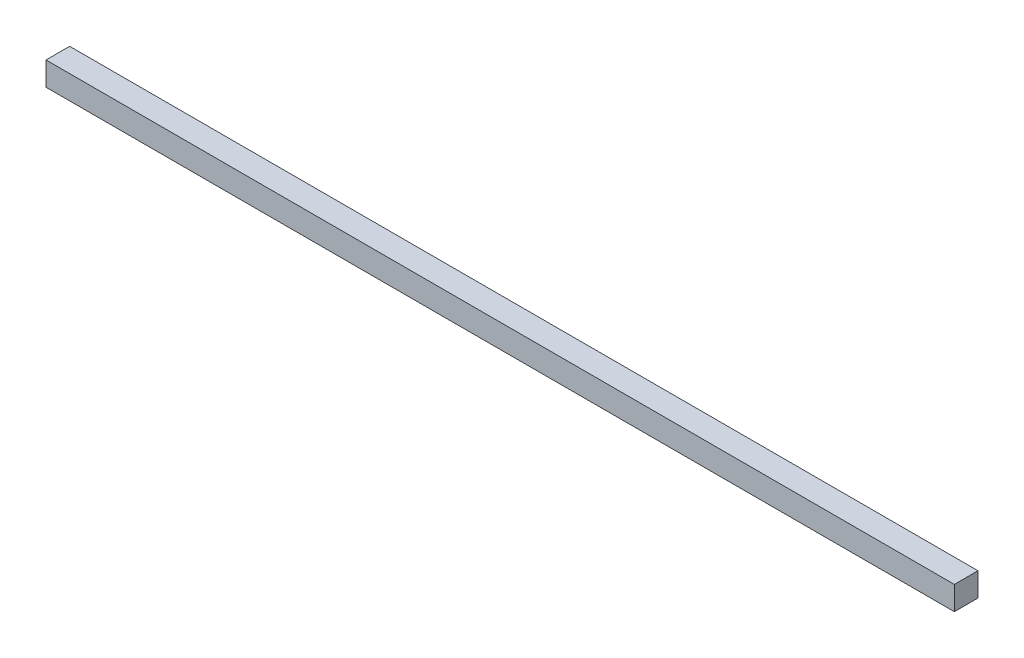
from build123d import *

# Parameters (mm, degrees)
SKETCH1_W           = 975.537386994
SKETCH1_H           = 25.4
BOSS_EXTRUDE1_DEPTH = 25.4


with BuildPart() as part:
    # Sketch1 → Boss-Extrude1 (new body)
    with BuildSketch(Plane(origin=(0, 0, 0), x_dir=(1, 0, 0), z_dir=(0, 1, 0))):
        with Locations((487.768693497, 12.7)):
            Rectangle(SKETCH1_W, SKETCH1_H)
    extrude(amount=BOSS_EXTRUDE1_DEPTH)


solid = part.part
